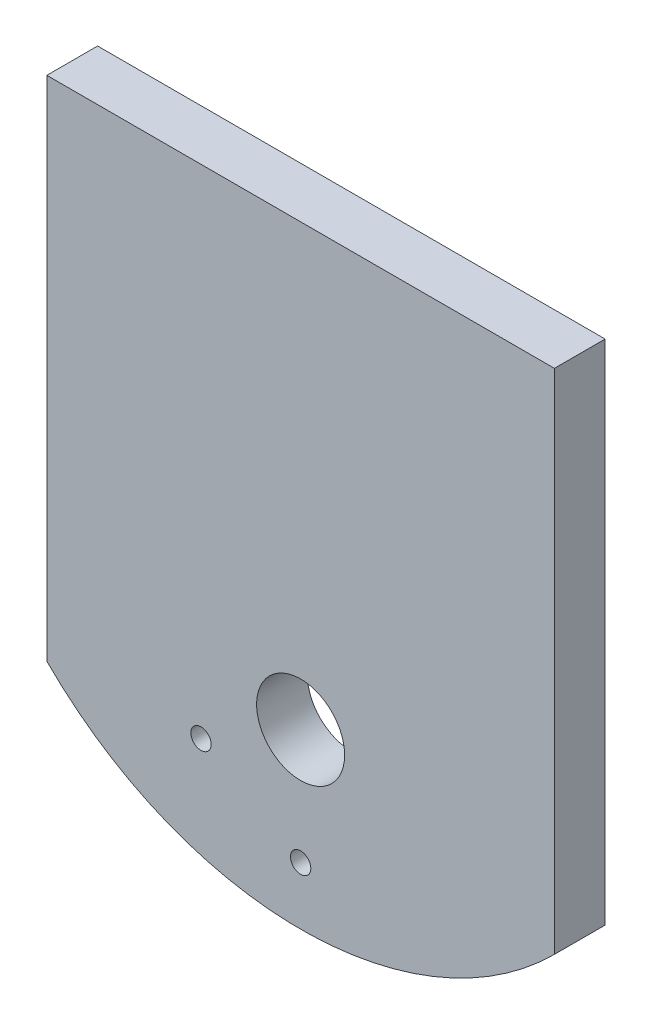
from build123d import *

# Parameters (mm, degrees)
SKETCH2_W                        = 150
SKETCH2_H                        = 90
SKETCH2_H_2                      = 60
BOSS_EXTRUDE1_DEPTH              = 15
SKETCH3_R                        = 13.005
SKETCH3_R_2                      = 3.01
CUT_EXTRUDE1_DEPTH               = 16
TAP_DRILL_FOR_M8X1_25_TAP1_D     = 6.8
TAP_DRILL_FOR_M8X1_25_TAP1_DEPTH = 10
TAP_DRILL_FOR_M8X1_25_TAP1_TIP   = 2.042926105


with BuildPart() as part:
    # Sketch2 → Boss-Extrude1 (new body)
    with BuildSketch(Plane.XY):
        Rectangle(SKETCH2_W, SKETCH2_H)
        with Locations((0, -75)):
            Rectangle(SKETCH2_W, SKETCH2_H_2)
        with BuildLine():
            Line((-75, -105), (75, -105))
            ThreePointArc((75, -105), (0, -136.066017178), (-75, -105))
        make_face()
    extrude(amount=BOSS_EXTRUDE1_DEPTH)

    # Sketch3 → Cut-Extrude1 (cut, through all)
    with BuildSketch(Plane.XY.offset(15)):
        with Locations((0, -85)):
            Circle(SKETCH3_R)
        with Locations((-29.444863729, -102)):
            Circle(SKETCH3_R_2)
        with Locations((0, -119)):
            Circle(SKETCH3_R_2)
    extrude(amount=-CUT_EXTRUDE1_DEPTH, mode=Mode.SUBTRACT)

    # Tap Drill for M8x1.25 Tap1
    with Locations(Plane(origin=(0, 0, 0), x_dir=(-1, 0, 0), z_dir=(0, 0, -1))):
        with Locations((-37.5, -50), (37.5, -50)):
            Hole(TAP_DRILL_FOR_M8X1_25_TAP1_D / 2, depth=TAP_DRILL_FOR_M8X1_25_TAP1_DEPTH)
            with Locations((0, 0, -(TAP_DRILL_FOR_M8X1_25_TAP1_DEPTH + TAP_DRILL_FOR_M8X1_25_TAP1_TIP / 2))):  # 118° drill point
                Cone(0, TAP_DRILL_FOR_M8X1_25_TAP1_D / 2, TAP_DRILL_FOR_M8X1_25_TAP1_TIP, mode=Mode.SUBTRACT)


solid = part.part
